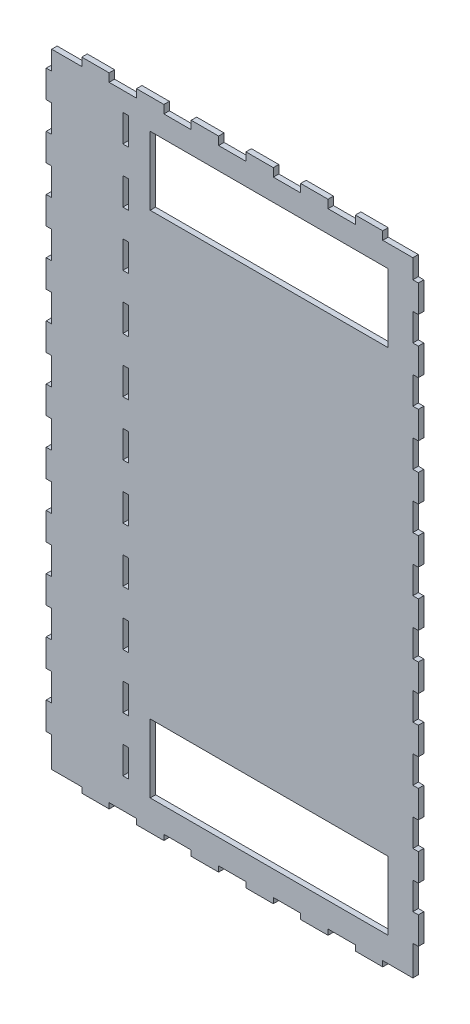
from build123d import *

# Parameters (mm, degrees)
SKETCH1_W           = 130
SKETCH1_H           = 227
SKETCH1_W_2         = 87
SKETCH1_H_2         = 25
BOSS_EXTRUDE1_DEPTH = 2
SKETCH2_W           = 10
SKETCH2_H           = 2
BOSS_EXTRUDE2_DEPTH = 3
LPATTERN1_COUNT     = 6
LPATTERN1_PITCH     = 20
SKETCH3_W           = 10
SKETCH3_H           = 2
BOSS_EXTRUDE3_DEPTH = 3
LPATTERN2_COUNT     = 6
LPATTERN2_PITCH     = 20
SKETCH4_W           = 2
SKETCH4_H           = 10
BOSS_EXTRUDE4_DEPTH = 3
LPATTERN3_COUNT     = 11
LPATTERN3_PITCH     = 20
SKETCH5_W           = 2
SKETCH5_H           = 10
BOSS_EXTRUDE5_DEPTH = 3
LPATTERN4_COUNT     = 11
LPATTERN4_PITCH     = 20
SKETCH6_W           = 3
SKETCH6_H           = 10
CUT_EXTRUDE1_DEPTH  = 3
LPATTERN5_COUNT     = 11
LPATTERN5_PITCH     = 20
ESQUISSE1_W         = 1
ESQUISSE1_H         = 210
ESQUISSE1_H_2       = 227
BOSS_EXTRU_1_DEPTH  = 2


with BuildPart() as part:
    # Sketch1 → Boss-Extrude1 (new body)
    with BuildSketch(Plane.XY):
        with Locations((65, 113.5)):
            Rectangle(SKETCH1_W, SKETCH1_H)
        with Locations((78.5, 20.5)):
            Rectangle(SKETCH1_W_2, SKETCH1_H_2, mode=Mode.SUBTRACT)
        with Locations((78.5, 206.5)):
            Rectangle(SKETCH1_W_2, SKETCH1_H_2, mode=Mode.SUBTRACT)
    extrude(amount=BOSS_EXTRUDE1_DEPTH)

    # Sketch2 → Boss-Extrude2 (add)
    with BuildSketch(Plane.XZ):
        with Locations((15, 1)):
            Rectangle(SKETCH2_W, SKETCH2_H)
    boss_extrude2 = extrude(amount=BOSS_EXTRUDE2_DEPTH)

    # LPattern1: Boss-Extrude2 ×6
    with Locations(*[(i * LPATTERN1_PITCH, 0, 0) for i in range(1, LPATTERN1_COUNT)]):
        add(boss_extrude2)

    # Sketch3 → Boss-Extrude3 (add)
    with BuildSketch(Plane(origin=(0, 227, 0), x_dir=(1, 0, 0), z_dir=(0, 1, 0))):
        with Locations((15, -1)):
            Rectangle(SKETCH3_W, SKETCH3_H)
    boss_extrude3 = extrude(amount=BOSS_EXTRUDE3_DEPTH)

    # LPattern2: Boss-Extrude3 ×6
    with Locations(*[(i * LPATTERN2_PITCH, 0, 0) for i in range(1, LPATTERN2_COUNT)]):
        add(boss_extrude3)

    # Sketch4 → Boss-Extrude4 (add)
    with BuildSketch(Plane(origin=(130, 0, 0), x_dir=(0, 0, -1), z_dir=(1, 0, 0))):
        with Locations((-1, 15)):
            Rectangle(SKETCH4_W, SKETCH4_H)
    boss_extrude4 = extrude(amount=BOSS_EXTRUDE4_DEPTH)

    # LPattern3: Boss-Extrude4 ×11
    with Locations(*[(0, i * LPATTERN3_PITCH, 0) for i in range(1, LPATTERN3_COUNT)]):
        add(boss_extrude4)

    # Sketch5 → Boss-Extrude5 (add)
    with BuildSketch(Plane.ZY):
        with Locations((1, 15)):
            Rectangle(SKETCH5_W, SKETCH5_H)
    boss_extrude5 = extrude(amount=BOSS_EXTRUDE5_DEPTH)

    # LPattern4: Boss-Extrude5 ×11
    with Locations(*[(0, i * LPATTERN4_PITCH, 0) for i in range(1, LPATTERN4_COUNT)]):
        add(boss_extrude5)

    # Sketch6 → Cut-Extrude1 (cut)
    with BuildSketch(Plane.XY.offset(2)):
        with Locations((26.5, 15)):
            Rectangle(SKETCH6_W, SKETCH6_H)
    cut_extrude1 = extrude(amount=-CUT_EXTRUDE1_DEPTH, mode=Mode.SUBTRACT)

    # LPattern5: Cut-Extrude1 ×11
    with Locations(*[(0, i * LPATTERN5_PITCH, 0) for i in range(1, LPATTERN5_COUNT)]):
        add(cut_extrude1, mode=Mode.SUBTRACT)

    # Esquisse1 → Boss.-Extru.1 (add)
    with BuildSketch(Plane.XY.offset(2)):
        Polygon((130, 0), (0, 0), (-1, 0), (-1, -1), (130, -1), align=None)
        with Locations((27.5, 115)):
            Rectangle(ESQUISSE1_W, ESQUISSE1_H)
        with Locations((-0.5, 113.5)):
            Rectangle(ESQUISSE1_W, ESQUISSE1_H_2)
        Polygon((130, 227), (130, 0), (130, -1), (131, -1), (131, 227), align=None)
    extrude(amount=-BOSS_EXTRU_1_DEPTH)


solid = part.part
